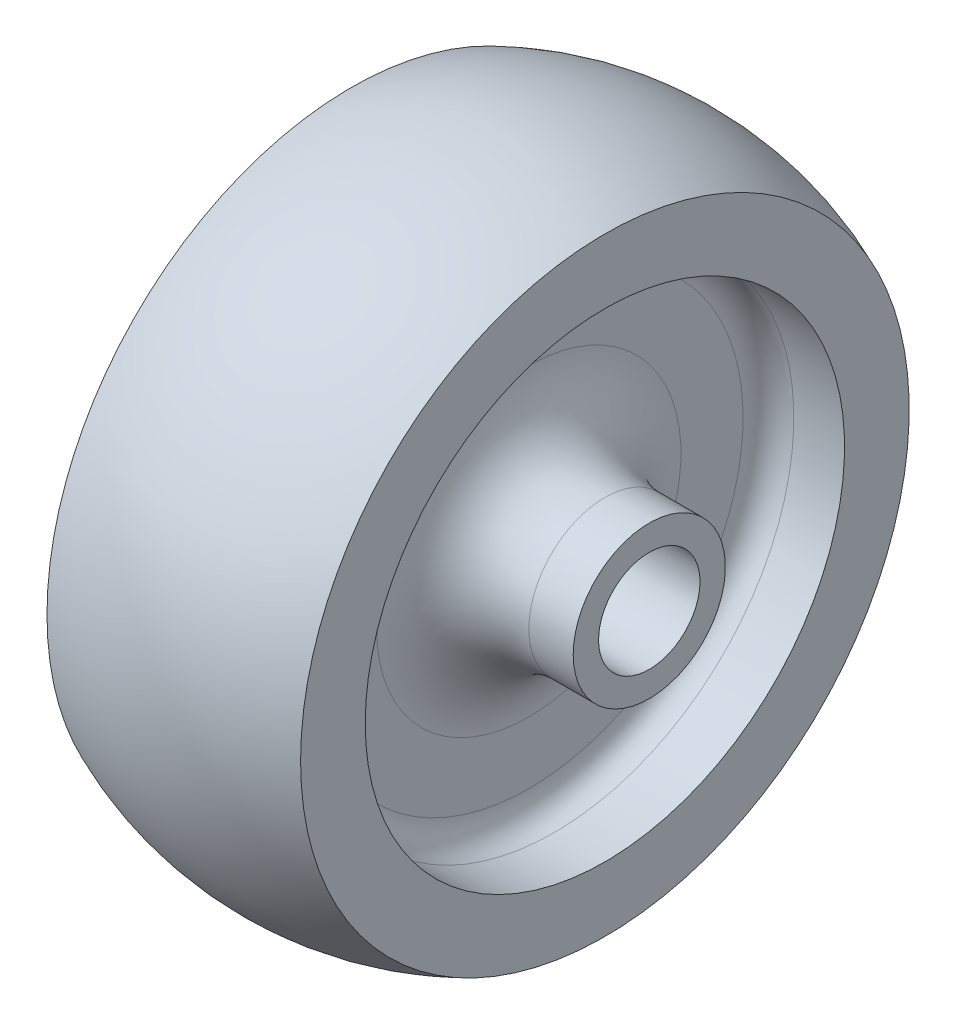
from build123d import *

# Parameters (mm, degrees)
FILLET1_R = 6


with BuildPart() as part:
    # Sketch1 → Revolve1 (revolve)
    with BuildSketch(Plane.XY):
        with BuildLine():
            Line((0, 4), (0, 6))
            Line((0, 6), (3.5, 6))
            Line((3.5, 6), (9.5, 6))
            Line((9.5, 6), (9.5, 16.9))
            ThreePointArc((9.5, 16.9), (8.914213562, 18.314213562), (7.5, 18.9))
            Line((7.5, 18.9), (3.5, 18.9))
            Line((3.5, 18.9), (3.5, 24))
            ThreePointArc((3.5, 24), (13.5, 26.087121525), (23.5, 24))
            Line((23.5, 24), (23.5, 18.9))
            Line((23.5, 18.9), (19.5, 18.9))
            ThreePointArc((19.5, 18.9), (18.085786438, 18.314213562), (17.5, 16.9))
            Line((17.5, 16.9), (17.5, 6))
            Line((17.5, 6), (23.5, 6))
            Line((23.5, 6), (27, 6))
            Line((27, 6), (27, 4))
            Line((27, 4), (0, 4))
        make_face()
    revolve(axis=Axis((0, 0, 0), (1, 0, 0)))

    # Fillet1
    fillet1_edges = [part.edges().sort_by_distance(p)[0] for p in [
        (9.5, -6, 0),
        (17.5, -6, 0),
    ]]
    fillet(fillet1_edges, radius=FILLET1_R)


solid = part.part
